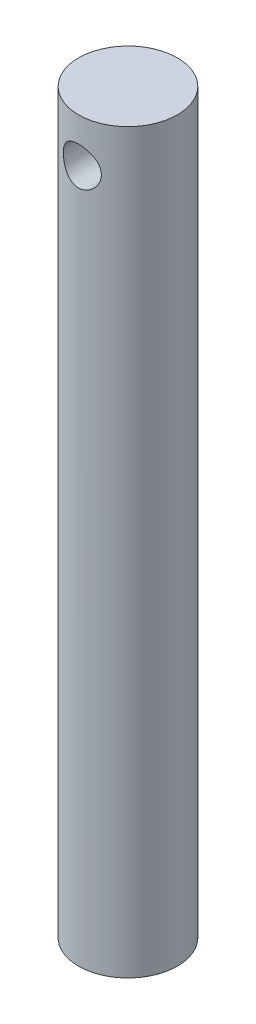
from build123d import *

# Parameters (mm, degrees)
SKETCH1_R               = 9.906
BOSS_EXTRUDE1_DEPTH     = 127
SKETCH2_R               = 9.906
BOSS_EXTRUDE2_DEPTH     = 20.828
CUT_EXTRUDE1_DEPTH      = 15.748
CUT_EXTRUDE1_DEPTH_BACK = 15.748
SKETCH3_R               = 3.81


with BuildPart() as part:
    # Sketch1 → Boss-Extrude1 (new body)
    with BuildSketch(Plane(origin=(0, 0, 0), x_dir=(1, 0, 0), z_dir=(0, 1, 0))):
        Circle(SKETCH1_R)
    extrude(amount=BOSS_EXTRUDE1_DEPTH)

    # Sketch2 → Boss-Extrude2 (add)
    with BuildSketch(Plane(origin=(0, 127, 0), x_dir=(1, 0, 0), z_dir=(0, 1, 0))):
        Circle(SKETCH2_R)
    extrude(amount=BOSS_EXTRUDE2_DEPTH)

    # Sketch3 → Cut-Extrude1 (cut, two sides: drawn at the far end of the back side and taken through both)
    with BuildSketch(Plane.XY.offset(-CUT_EXTRUDE1_DEPTH_BACK)):
        with Locations((0, 138.938)):
            Circle(SKETCH3_R)
    extrude(amount=CUT_EXTRUDE1_DEPTH + CUT_EXTRUDE1_DEPTH_BACK, mode=Mode.SUBTRACT)


solid = part.part
